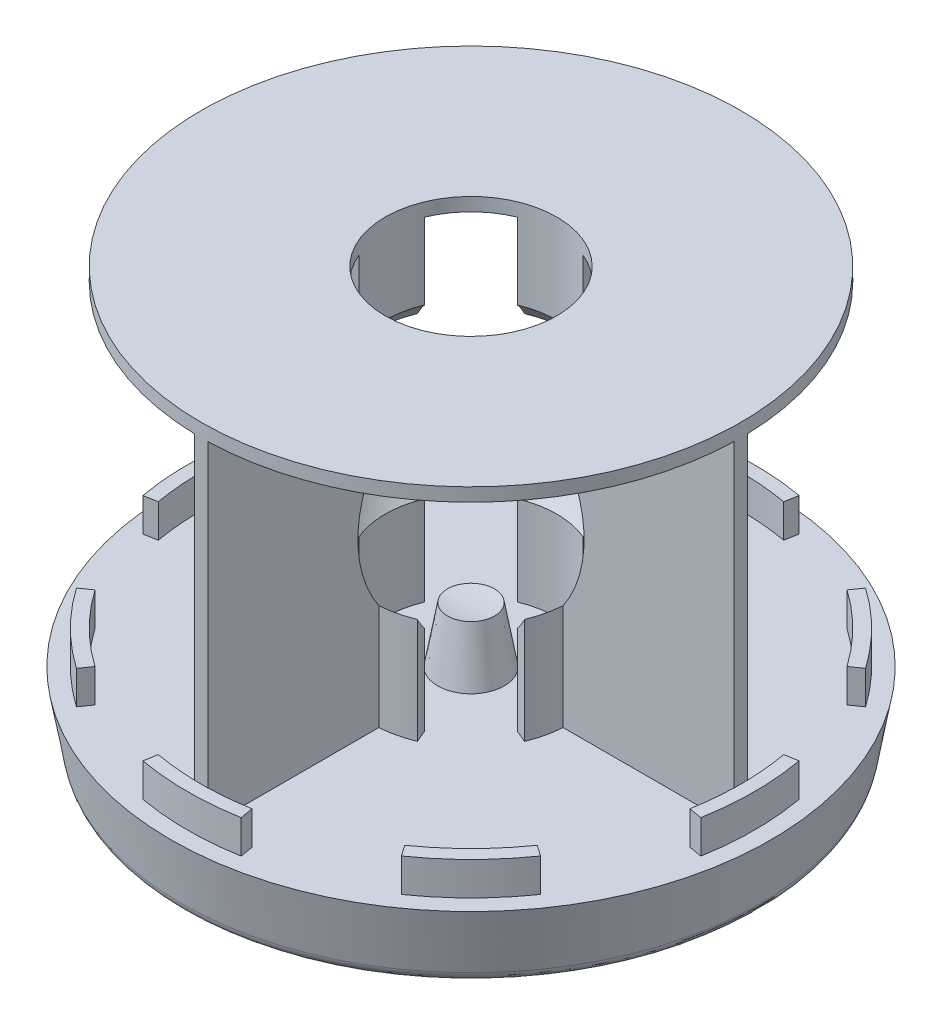
from build123d import *

# Parameters (mm, degrees)
SKETCH1_R           = 2250
BOSS_EXTRUDE1_DEPTH = 500
BOSS_EXTRUDE1_TAPER = 10
SKETCH2_R           = 2161.83651
BOSS_EXTRUDE2_DEPTH = 500
BOSS_EXTRUDE2_TAPER = 60
FILLET1_R           = 100
BOSS_EXTRUDE3_DEPTH = 250
CIRPATTERN1_COUNT   = 8
BOSS_EXTRUDE5_DEPTH = 2500
CIRPATTERN2_COUNT   = 4
SKETCH6_R           = 2025
SKETCH6_R_2         = 643.060761
BOSS_EXTRUDE6_DEPTH = 100
SKETCH9_R           = 250
BOSS_EXTRUDE7_DEPTH = 500
BOSS_EXTRUDE7_TAPER = 10


with BuildPart() as part:
    # Sketch1 → Boss-Extrude1 (new body)
    with BuildSketch(Plane(origin=(0, 0, 0), x_dir=(1, 0, 0), z_dir=(0, 1, 0))):
        Circle(SKETCH1_R)
    extrude(amount=-BOSS_EXTRUDE1_DEPTH, taper=BOSS_EXTRUDE1_TAPER)

    # Sketch2 → Boss-Extrude2 (add)
    with BuildSketch(Plane.XZ.offset(500)):
        Circle(SKETCH2_R)
    extrude(amount=BOSS_EXTRUDE2_DEPTH, taper=BOSS_EXTRUDE2_TAPER)

    # Fillet1
    fillet1_edges = [part.edges().sort_by_distance(p)[0] for p in [
        (-2161.83651, -500, 0),
    ]]
    fillet(fillet1_edges, radius=FILLET1_R)

    # Sketch3 → Boss-Extrude3 (add)
    with BuildSketch(Plane(origin=(0, 0, 0), x_dir=(1, 0, 0), z_dir=(0, 1, 0))):
        with BuildLine():
            Line((0, 2125), (0, 2025))
            ThreePointArc((0, 2025), (176.490379, 2017.294264), (351.63756, 1994.2357))
            Line((351.63756, 1994.2357), (369.002378, 2092.716475))
            ThreePointArc((369.002378, 2092.716475), (185.205953, 2116.913733), (0, 2125))
        make_face()
        with BuildLine():
            ThreePointArc((-351.63756, 1994.2357), (-176.490379, 2017.294264), (0, 2025))
            Line((0, 2025), (0, 2125))
            ThreePointArc((0, 2125), (-185.205953, 2116.913733), (-369.002378, 2092.716475))
            Line((-369.002378, 2092.716475), (-351.63756, 1994.2357))
        make_face()
    boss_extrude3 = extrude(amount=BOSS_EXTRUDE3_DEPTH)

    # CirPattern1: Boss-Extrude3 ×8 about axis
    cirpattern1_axis = Axis((0, 0, 0), (0, 1, 0))
    for i in range(1, CIRPATTERN1_COUNT):
        add(boss_extrude3.rotate(cirpattern1_axis, i * 360 / CIRPATTERN1_COUNT))

    # Sketch5 → Boss-Extrude5 (add)
    with BuildSketch(Plane(origin=(0, 0, 0), x_dir=(1, 0, 0), z_dir=(0, 1, 0))):
        with BuildLine():
            Line((50, 741.376622), (50, 743.060761))
            Line((50, 743.060761), (50, 2024.382622))
            ThreePointArc((50, 2024.382622), (25.001906, 2024.84565), (0, 2025))
            ThreePointArc((0, 2025), (-25.001906, 2024.84565), (-50, 2024.382622))
            Line((-50, 2024.382622), (-50, 743.060761))
            Line((-50, 743.060761), (-50, 741.376622))
            ThreePointArc((-50, 741.376622), (-169.415337, 723.489971), (-284.357043, 686.498629))
            Line((-284.357043, 686.498629), (-246.088699, 594.110676))
            ThreePointArc((-246.088699, 594.110676), (0, 643.060761), (246.088699, 594.110676))
            Line((246.088699, 594.110676), (284.357043, 686.498629))
            ThreePointArc((284.357043, 686.498629), (169.415337, 723.489971), (50, 741.376622))
        make_face()
    boss_extrude5 = extrude(amount=BOSS_EXTRUDE5_DEPTH)

    # CirPattern2: Boss-Extrude5 ×4 about axis
    cirpattern2_axis = Axis((0, 0, 0), (0, 1, 0))
    for i in range(1, CIRPATTERN2_COUNT):
        add(boss_extrude5.rotate(cirpattern2_axis, i * 360 / CIRPATTERN2_COUNT))

    # Sketch6 → Boss-Extrude6 (add)
    with BuildSketch(Plane(origin=(0, 2500, 0), x_dir=(1, 0, 0), z_dir=(0, 1, 0))):
        Circle(SKETCH6_R)
        Circle(SKETCH6_R_2, mode=Mode.SUBTRACT)
    extrude(amount=BOSS_EXTRUDE6_DEPTH)

    # Sketch9 → Boss-Extrude7 (add)
    with BuildSketch(Plane(origin=(0, 0, 0), x_dir=(1, 0, 0), z_dir=(0, 1, 0))):
        Circle(SKETCH9_R)
    extrude(amount=BOSS_EXTRUDE7_DEPTH, taper=BOSS_EXTRUDE7_TAPER)

    # Sketch7 → Cut-Revolve2 (revolve, cut)
    with BuildSketch(Plane.XY):
        with BuildLine():
            Line((0, 2200), (0, 400))
            ThreePointArc((0, 400), (900, 1300), (0, 2200))
        make_face()
    revolve(axis=Axis((0, -1000, 0), (0, 1, 0)), mode=Mode.SUBTRACT)


solid = part.part
